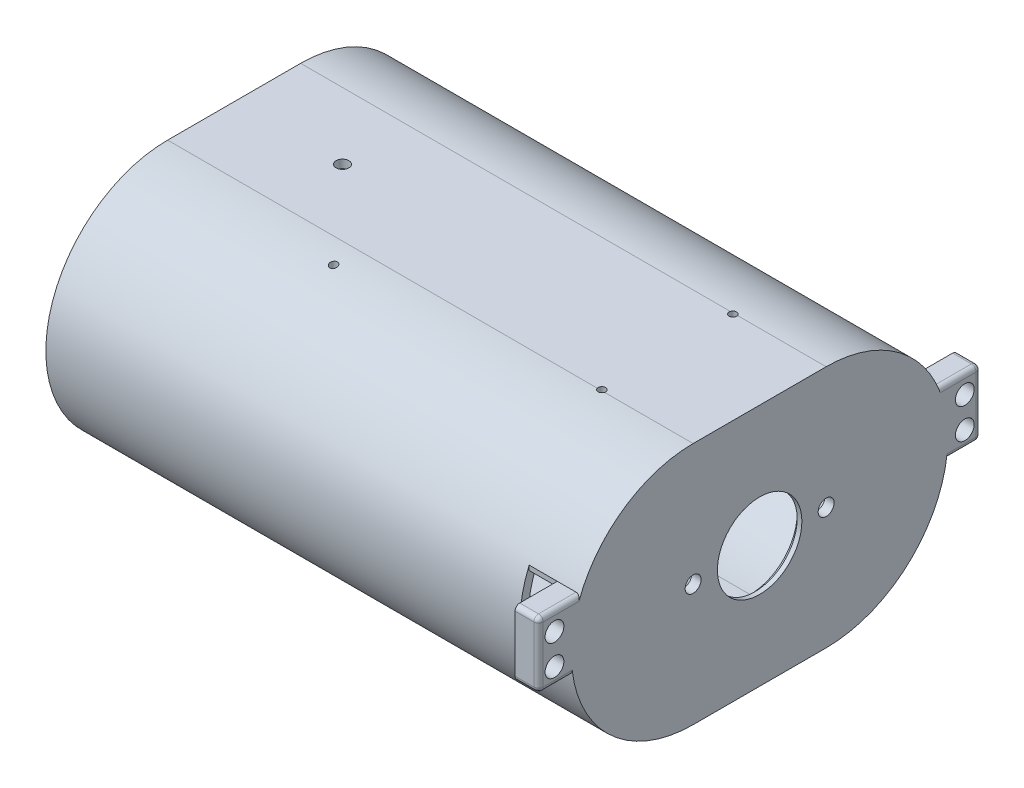
from build123d import *

# Parameters (mm, degrees)
BOSS_EXTRUDE1_DEPTH  = 110
SKETCH5_R            = 1.7
BOSS_EXTRUDE2_DEPTH  = 2
CUT_EXTRUDE2_DEPTH   = 122.768226263
SKETCH7_R            = 1.35
CUT_EXTRUDE3_DEPTH   = 10
SKETCH8_R            = 1.35
CUT_EXTRUDE4_DEPTH   = 18
SKETCH9_R            = 1.35
CUT_EXTRUDE5_DEPTH   = 20
CHAMFER3_SIZE        = 1
CUT_EXTRUDE6_DEPTH   = 30
SKETCH17_R           = 0.8
CUT_EXTRUDE11_DEPTH  = 10
SKETCH19_W           = 6
SKETCH19_H           = 20
CUT_EXTRUDE12_DEPTH  = 2
BOSS_EXTRUDE3_DEPTH  = 5
FILLET1_R            = 1
FILLET1_OF_MIRROR2_R = 1
BOSS_EXTRUDE4_DEPTH  = 6
SKETCH22_W           = 6
SKETCH22_H           = 5.520484943
CUT_EXTRUDE13_DEPTH  = 142.567358074


with BuildPart() as part:
    # Sketch1 → Boss-Extrude1 (new body)
    with BuildSketch(Plane(origin=(0, 0, 0), x_dir=(0, 0, -1), z_dir=(1, 0, 0))):
        with BuildLine():
            Line((-14.176031791, 25.95), (14.176031791, 25.95))
            ThreePointArc((14.176031791, 25.95), (40.126031791, 0), (14.176031791, -25.95))
            Line((14.176031791, -25.95), (-14.176031791, -25.95))
            ThreePointArc((-14.176031791, -25.95), (-40.126031791, 0), (-14.176031791, 25.95))
        make_face()
        with BuildLine():
            ThreePointArc((14.176031791, -24.2), (38.376031791, 0), (14.176031791, 24.2))
            Line((14.176031791, 24.2), (-14.176031791, 24.2))
            ThreePointArc((-14.176031791, 24.2), (-38.376031791, 0), (-14.176031791, -24.2))
            Line((-14.176031791, -24.2), (14.176031791, -24.2))
        make_face(mode=Mode.SUBTRACT)
    extrude(amount=-BOSS_EXTRUDE1_DEPTH)

    # Sketch5 → Boss-Extrude2 (add)
    with BuildSketch(Plane(origin=(0, 0, 0), x_dir=(0, 0, -1), z_dir=(1, 0, 0))):
        with BuildLine():
            Line((14.176031791, 25.95), (-14.176031791, 25.95))
            ThreePointArc((-14.176031791, 25.95), (-40.126031791, 0), (-14.176031791, -25.95))
            Line((-14.176031791, -25.95), (14.176031791, -25.95))
            ThreePointArc((14.176031791, -25.95), (40.126031791, 0), (14.176031791, 25.95))
        make_face()
        with Locations((-14.176031791, 0)):
            Circle(SKETCH5_R, mode=Mode.SUBTRACT)
        with Locations((14.176031791, 0)):
            Circle(SKETCH5_R, mode=Mode.SUBTRACT)
    extrude(amount=BOSS_EXTRUDE2_DEPTH)

    # Sketch6 → Cut-Extrude2 (cut, through all)
    with BuildSketch(Plane(origin=(2, 0, 0), x_dir=(0, 0, -1), z_dir=(1, 0, 0))):
        with BuildLine():
            Line((8.197732319, -3.714456195), (-8.197732319, -3.714456195))
            ThreePointArc((-8.197732319, -3.714456195), (0, -9), (8.197732319, -3.714456195))
        make_face()
        with BuildLine():
            ThreePointArc((-8.197732319, 3.714456195), (-9, 0), (-8.197732319, -3.714456195))
            Line((-8.197732319, -3.714456195), (8.197732319, -3.714456195))
            ThreePointArc((8.197732319, -3.714456195), (8.797147005, -1.900053832), (9, 0))
            ThreePointArc((9, 0), (8.797147005, 1.900053832), (8.197732319, 3.714456195))
            Line((8.197732319, 3.714456195), (-8.197732319, 3.714456195))
        make_face()
        with BuildLine():
            ThreePointArc((8.197732319, 3.714456195), (0, 9), (-8.197732319, 3.714456195))
            Line((-8.197732319, 3.714456195), (8.197732319, 3.714456195))
        make_face()
    extrude(amount=-CUT_EXTRUDE2_DEPTH, mode=Mode.SUBTRACT)

    # Sketch7 → Cut-Extrude3 (cut)
    with BuildSketch(Plane(origin=(0, 25.95, 0), x_dir=(1, 0, 0), z_dir=(0, 1, 0))):
        with Locations(Location((-86.907808055, 0, 0), (0, 0, 270))):
            Circle(SKETCH7_R)
    extrude(amount=-CUT_EXTRUDE3_DEPTH, mode=Mode.SUBTRACT)

    # Sketch8 → Cut-Extrude4 (cut)
    with BuildSketch(Plane(origin=(-81.2, -21.801570971, 13.800859089), x_dir=(0, -0.5348639046580952, -0.8449382246613631), z_dir=(0, -0.8449382246613631, 0.5348639046580952))):
        with Locations(Location((-11.851715909, -5.707808055, 0), (0, 0, 180))):
            Circle(SKETCH8_R)
    extrude(amount=CUT_EXTRUDE4_DEPTH, mode=Mode.SUBTRACT)

    # Sketch9 → Cut-Extrude5 (cut)
    with BuildSketch(Plane(origin=(-81.2, -20.415869871, -18.919341673), x_dir=(0, 0.6797127918842137, -0.7334783708801288), z_dir=(0, -0.7334783708801288, -0.6797127918842137))):
        with Locations(Location((10.288299219, -5.707808055, 0), (0, 0, 180))):
            Circle(SKETCH9_R)
    extrude(amount=CUT_EXTRUDE5_DEPTH, mode=Mode.SUBTRACT)

    # Chamfer3
    chamfer3_edges = [part.edges().sort_by_distance(p)[0] for p in [
        (0, -3.714456195, 8.197732319),
    ]]
    chamfer(chamfer3_edges, length=CHAMFER3_SIZE)

    # Sketch11 → Cut-Extrude6 (cut)
    with BuildSketch(Plane.ZY.offset(110)):
        with BuildLine():
            Line((34.47, 13.05), (34.47, 12.05))
            Line((34.47, 12.05), (35.16263466, 12.05))
            ThreePointArc((35.16263466, 12.05), (34.865291248, 12.553666521), (34.555862506, 13.05))
            Line((34.555862506, 13.05), (34.47, 13.05))
        make_face()
        with BuildLine():
            ThreePointArc((34.555862506, 13.05), (34.865291248, 12.553666521), (35.16263466, 12.05))
            Line((35.16263466, 12.05), (35.47, 12.05))
            Line((35.47, 12.05), (35.47, 13.05))
            Line((35.47, 13.05), (34.555862506, 13.05))
        make_face()
        with BuildLine():
            Line((35.47, 12.05), (35.16263466, 12.05))
            ThreePointArc((35.16263466, 12.05), (35.318118105, 11.775066296), (35.47, 11.498126712))
            Line((35.47, 11.498126712), (35.47, 12.05))
        make_face()
        with BuildLine():
            Line((35.16263466, 12.05), (34.47, 12.05))
            Line((34.47, 12.05), (34.47, 10.910793812))
            Line((34.47, 10.910793812), (35.47, 10.910793812))
            Line((35.47, 10.910793812), (35.47, 11.498126712))
            ThreePointArc((35.47, 11.498126712), (35.318118105, 11.775066296), (35.16263466, 12.05))
        make_face()
    extrude(amount=-CUT_EXTRUDE6_DEPTH, mode=Mode.SUBTRACT)

    # Sketch17 → Cut-Extrude11 (cut)
    with BuildSketch(Plane(origin=(0, 25.95, 0), x_dir=(1, 0, 0), z_dir=(0, 1, 0))):
        with Locations(Location((-17.658223223, 13.95, 0), (0, 0, 16.411842871))):
            Circle(SKETCH17_R)
        with Locations(Location((-17.658223223, -13.95, 0), (0, 0, 196.411842871))):
            Circle(SKETCH17_R)
        with Locations(Location((-69.758223223, -19.05, 0), (0, 0, 270))):
            Circle(SKETCH17_R)
    extrude(amount=-CUT_EXTRUDE11_DEPTH, mode=Mode.SUBTRACT)

    # Sketch19 → Cut-Extrude12 (cut)
    with BuildSketch(Plane(origin=(0, 0, -40.126031791), x_dir=(-1, 0, 0), z_dir=(0, 0, -1))):
        with Locations((6, 0)):
            Rectangle(SKETCH19_W, SKETCH19_H)
    cut_extrude12 = extrude(amount=-CUT_EXTRUDE12_DEPTH, mode=Mode.SUBTRACT)

    # Mirror1: Cut-Extrude12 across plane
    add(cut_extrude12.mirror(Plane.XY), mode=Mode.SUBTRACT)

    # Sketch20 → Boss-Extrude3 (add)
    with BuildSketch(Plane.ZY.offset(3)):
        with BuildLine():
            Line((-46.126031791, -4.010005005), (-39.814330483, -4.010005005))
            ThreePointArc((-39.814330483, -4.010005005), (-39.939374777, 3.106872735), (-38.126031791, 9.989994995))
            Line((-38.126031791, 9.989994995), (-46.126031791, 9.989994995))
            ThreePointArc((-46.126031791, 9.989994995), (-46.833138572, 9.697101776), (-47.126031791, 8.989994995))
            Line((-47.126031791, 8.989994995), (-47.126031791, -3.010005005))
            ThreePointArc((-47.126031791, -3.010005005), (-46.833138572, -3.717111786), (-46.126031791, -4.010005005))
        make_face()
        with BuildLine():
            ThreePointArc((-45.726031791, -0.469510052), (-43.726031791, 1.530489948), (-41.726031791, -0.469510052))
            ThreePointArc((-41.726031791, -0.469510052), (-43.726031791, -2.469510052), (-45.726031791, -0.469510052))
        make_face(mode=Mode.SUBTRACT)
        with BuildLine():
            ThreePointArc((-45.726031791, 6.030489948), (-43.726031791, 8.030489948), (-41.726031791, 6.030489948))
            ThreePointArc((-41.726031791, 6.030489948), (-43.726031791, 4.030489948), (-45.726031791, 6.030489948))
        make_face(mode=Mode.SUBTRACT)
    boss_extrude3 = extrude(amount=-BOSS_EXTRUDE3_DEPTH)

    # Fillet1
    fillet1_edges = [part.edges().sort_by_distance(p)[0] for p in [
        (2, 9.989994995, -42.126031791),
        (2, -3.717111786, -46.833138572),
        (2, 9.697101776, -46.833138572),
        (2, -4.010005005, -42.970181137),
        (2, 2.989994995, -47.126031791),
    ]]
    fillet(fillet1_edges, radius=FILLET1_R)

    # Mirror2: Boss-Extrude3 across plane
    add(boss_extrude3.mirror(Plane.XY))

    # Fillet1 of Mirror2
    fillet1_of_mirror2_edges = [part.edges().sort_by_distance(p)[0] for p in [
        (2, 9.989994995, 42.126031791),
        (2, -3.717111786, 46.833138572),
        (2, 9.697101776, 46.833138572),
        (2, -4.010005005, 42.970181137),
        (2, 2.989994995, 47.126031791),
    ]]
    fillet(fillet1_of_mirror2_edges, radius=FILLET1_OF_MIRROR2_R)

    # Sketch21 → Boss-Extrude4 (add)
    with BuildSketch(Plane.ZY.offset(3)):
        with BuildLine():
            Line((-39.814330483, -4.010005005), (-38.126031791, -4.010005005))
            Line((-38.126031791, -4.010005005), (-38.126031791, -9.989994995))
            ThreePointArc((-38.126031791, -9.989994995), (-39.149816283, -7.050715433), (-39.814330483, -4.010005005))
        make_face()
        with BuildLine():
            Line((38.126031791, -4.010005005), (38.126031791, -9.989994995))
            ThreePointArc((38.126031791, -9.989994995), (39.149816283, -7.050715433), (39.814330483, -4.010005005))
            Line((39.814330483, -4.010005005), (38.126031791, -4.010005005))
        make_face()
    extrude(amount=BOSS_EXTRUDE4_DEPTH)

    # Sketch22 → Cut-Extrude13 (cut, through all)
    with BuildSketch(Plane(origin=(0, 0, -38.126031791), x_dir=(-1, 0, 0), z_dir=(0, 0, -1))):
        with Locations((6, 6.229752524)):
            Rectangle(SKETCH22_W, SKETCH22_H)
    extrude(amount=-CUT_EXTRUDE13_DEPTH, mode=Mode.SUBTRACT)


solid = part.part
